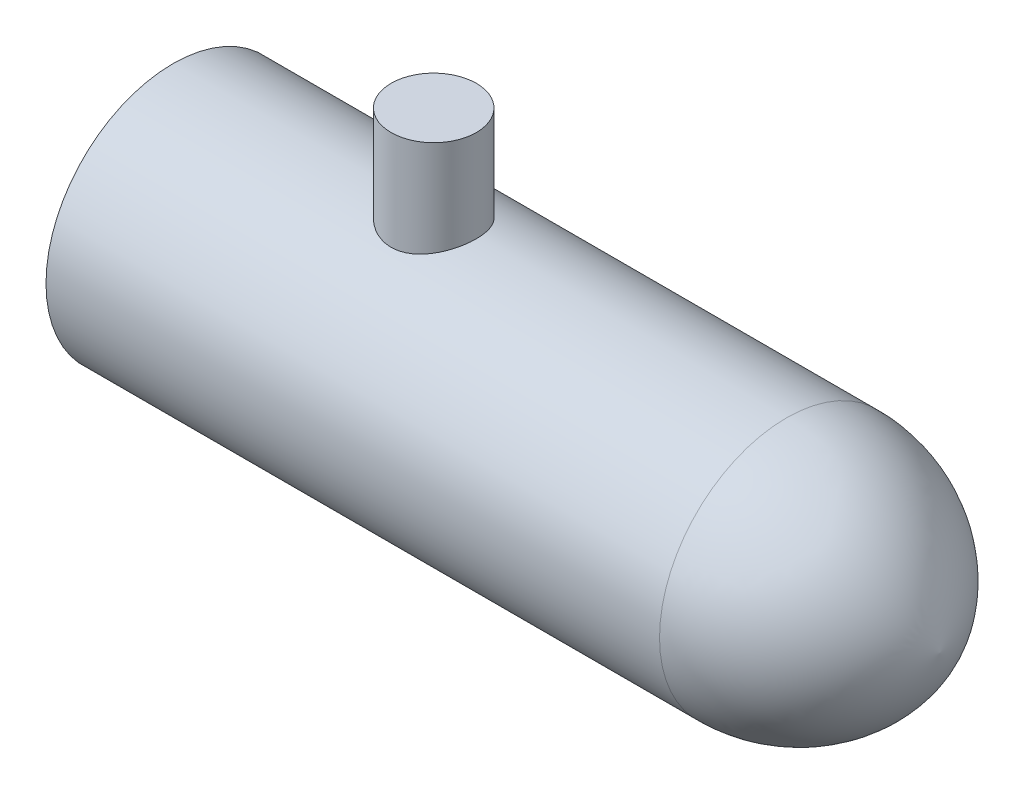
from build123d import *

# Parameters (mm, degrees)
SKETCH1_R           = 52.5526
BOSS_EXTRUDE1_DEPTH = 127
BOSS_EXTRUDE2_START = -3.053637
SKETCH4_R           = 17.653
BOSS_EXTRUDE2_DEPTH = 41.153637


with BuildPart() as part:
    # Sketch1 → Boss-Extrude1 (new body, symmetric)
    with BuildSketch(Plane(origin=(0, 0, 0), x_dir=(0, 0, -1), z_dir=(1, 0, 0))):
        Circle(SKETCH1_R)
    extrude(amount=BOSS_EXTRUDE1_DEPTH, both=True)

    # Sketch2 → Revolve1 (revolve)
    with BuildSketch(Plane.XY):
        with BuildLine():
            Line((127, 52.5526), (127, 0))
            Line((127, 0), (190.5, 0))
            ThreePointArc((190.5, 0), (168.212940221, 37.710495531), (127, 52.5526))
        make_face()
    revolve(axis=Axis((127, 0, 0), (1, 0, 0)))

    # Sketch4 → Boss-Extrude2 (add)
    with BuildSketch(Plane(origin=(0, 52.5526, 0), x_dir=(1, 0, 0), z_dir=(0, 1, 0)).offset(BOSS_EXTRUDE2_START)):
        with Locations((-19.05, 0)):
            Circle(SKETCH4_R)
    extrude(amount=BOSS_EXTRUDE2_DEPTH)


solid = part.part
